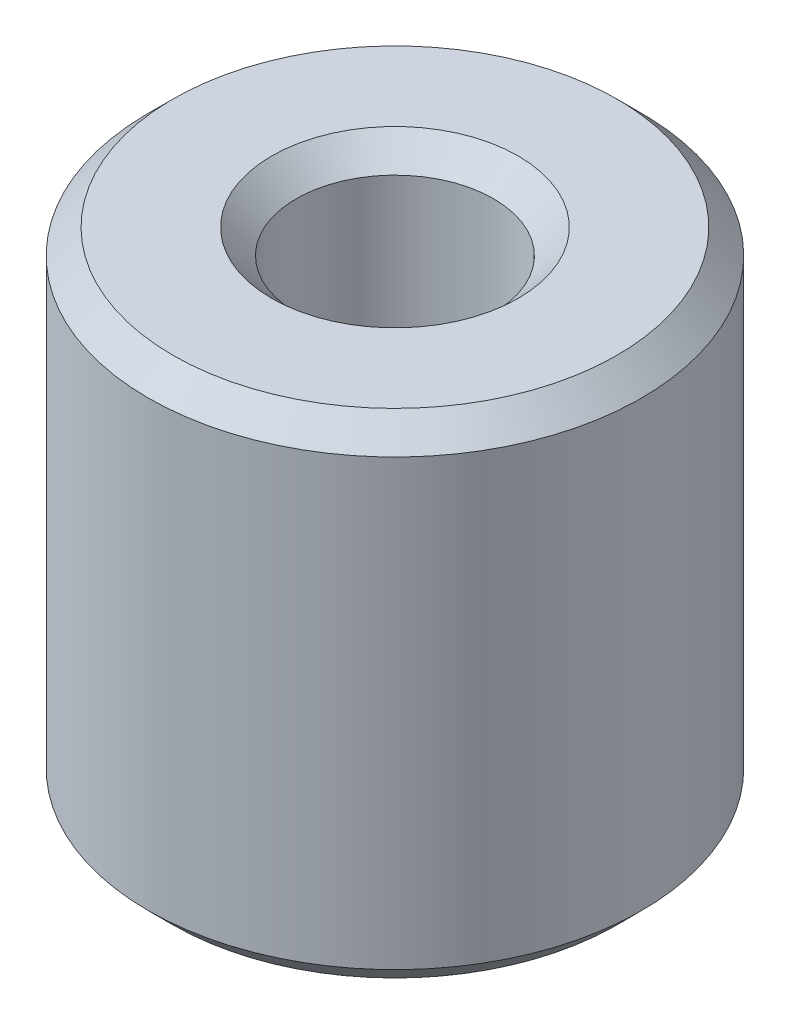
from build123d import *

# Parameters (mm, degrees)
SKETCH1_R           = 4
SKETCH1_R_2         = 1.6
BOSS_EXTRUDE1_DEPTH = 8
CHAMFER1_SIZE       = 0.4


with BuildPart() as part:
    # Sketch1 → Boss-Extrude1 (new body)
    with BuildSketch(Plane(origin=(0, 0, 0), x_dir=(1, 0, 0), z_dir=(0, 1, 0))):
        Circle(SKETCH1_R)
        Circle(SKETCH1_R_2, mode=Mode.SUBTRACT)
    extrude(amount=BOSS_EXTRUDE1_DEPTH)

    # Chamfer1
    chamfer1_edges = [part.edges().sort_by_distance(p)[0] for p in [
        (-4, 0, 0),
        (-4, 8, 0),
        (-1.6, 0, 0),
        (-1.6, 8, 0),
    ]]
    chamfer(chamfer1_edges, length=CHAMFER1_SIZE)


solid = part.part
